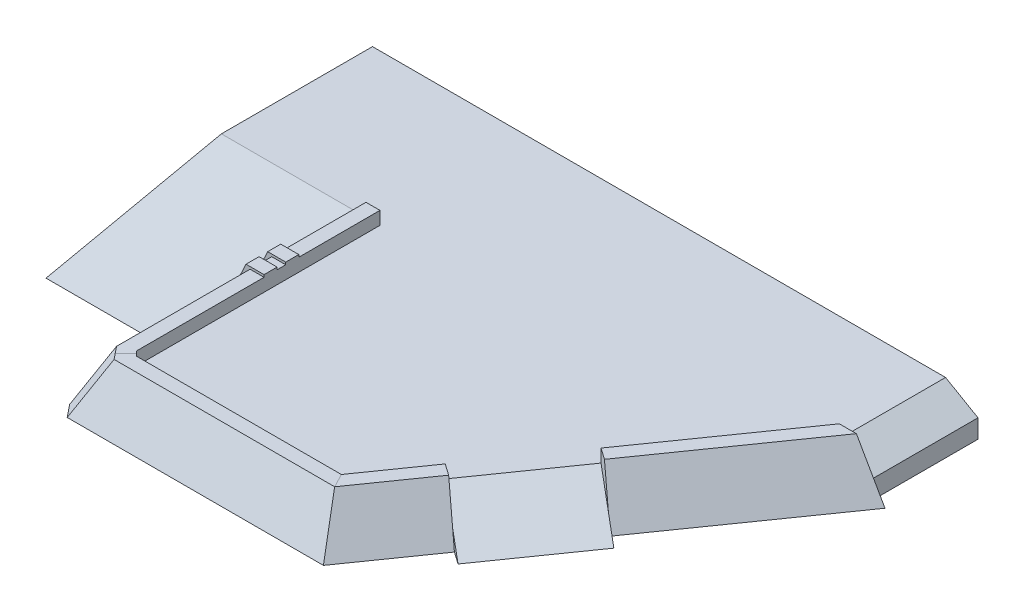
from build123d import *

# Parameters (mm, degrees)
EXTRUDE_1_DEPTH        = 400
EXTRUDE_2_DEPTH        = 1701
EXTRUDE_3_DEPTH        = 1140.074385
CUT_EXTRUDE_1_DEPTH    = 1140.074385
CHAMFER_1_SIZE2        = 124.175097768
CHAMFER_1_SIZE         = 100
CHAMFER_2_SIZE         = 50
EXTRUDE_START          = -870.9
EXTRUDE_4_DEPTH        = 140
PATTERN_LINEAR_1_COUNT = 2
PATTERN_LINEAR_1_PITCH = 232.7
EXTRUDE_START_2        = -800
EXTRUDE_5_DEPTH        = 1200
CUT_EXTRUDE_START      = -800
CUT_EXTRUDE_2_DEPTH    = 1200
CUT_EXTRUDE_START_2    = 6495.820323
SKETCH_9_W             = 1140.074385167
SKETCH_9_H             = 400
CUT_EXTRUDE_3_DEPTH    = 345


with BuildPart() as part:
    # Sketch 1 → Extrude 1 (new body)
    with BuildSketch(Plane(origin=(0, 0, 0), x_dir=(1, 0, 0), z_dir=(0, 1, 0))):
        Polygon((0, 0), (6148, 0), (6148, -1140.074385167), (3948, -4282), (1701, -4282), (1701, -1621), (0, -1621), align=None)
    extrude(amount=EXTRUDE_1_DEPTH)

    # Sketch 2 → Extrude 2 (add)
    with BuildSketch(Plane.ZY.offset(-1701)):
        Polygon((1621, 400), (3502.852043791, 0), (1621, 0), align=None)
    extrude(amount=EXTRUDE_2_DEPTH)

    # Sketch 3 → Extrude 3 (add)
    with BuildSketch(Plane(origin=(0, 0, 0), x_dir=(-1, 0, 0), z_dir=(0, 0, -1))):
        Polygon((-6148, 400), (-6148, 0), (-6840.820323028, 0), align=None)
    extrude(amount=-EXTRUDE_3_DEPTH)

    # Sweep 2: sweep along a path in Sketch 5
    with BuildLine(Plane(origin=(0, 400, 0), x_dir=(1, 0, 0), z_dir=(0, 1, 0))) as sweep_2_path:
        Line((1701, -1621), (1701, -4282))
        Line((1701, -4282), (3948, -4282))
        Line((3948, -4282), (6434.788218176, -730.498363023))
    # Sketch 4 → Sweep 2 (sweep)
    with BuildSketch(Plane.XY.offset(3282)):
        Polygon((1701, 400), (1701, 539.392949833), (1551, 539.392949833), (1299.476936738, 0), (1701, 0), align=None)
    sweep(path=sweep_2_path.line, transition=Transition.RIGHT)

    # Sketch 6 → Cut-Extrude 1 (cut)
    with BuildSketch(Plane(origin=(0, 0, 0), x_dir=(-1, 0, 0), z_dir=(0, 0, -1))):
        Polygon((-6148, 400), (-6148, 600), (-6840.820323028, 600), (-6840.820323028, 0), align=None)
    extrude(amount=-CUT_EXTRUDE_1_DEPTH, mode=Mode.SUBTRACT)

    # Chamfer 1
    chamfer_1_edges = [part.edges().sort_by_distance(p)[0] for p in [
        (1425.238468369, 269.696474917, 4557.761531631),
    ]]
    chamfer(chamfer_1_edges, length=CHAMFER_1_SIZE, length2=CHAMFER_1_SIZE2)

    # Chamfer 2
    chamfer_2_edges = [part.edges().sort_by_distance(p)[0] for p in [
        (1701, 469.696474917, 4282),
    ]]
    chamfer(chamfer_2_edges, length=CHAMFER_2_SIZE)

    # Sketch 7 → Extrude 4 (add)
    with BuildSketch(Plane(origin=(0, 0, 1621), x_dir=(-1, 0, 0), z_dir=(0, 0, -1)).offset(EXTRUDE_START)):
        Polygon((-1701, 0), (-1701, 564.392949833), (-1507.488795506, 564.392949833), (-1244.30804079, 0), align=None)
    extrude_4 = extrude(amount=-EXTRUDE_4_DEPTH)

    # Pattern Linear 1: Extrude 4 ×2
    with Locations(*[(0, 0, i * PATTERN_LINEAR_1_PITCH) for i in range(1, PATTERN_LINEAR_1_COUNT)]):
        add(extrude_4)

    # Sketch 8 → Extrude 5 (add)
    with BuildSketch(Plane(origin=(3948, 539.392949833, 4282), x_dir=(0.819152044, 0, 0.573576436), z_dir=(-0.573576436, 0, 0.819152044)).offset(EXTRUDE_START_2)):
        Polygon((0, -539.392949833), (0, -139.392949833), (560.779317791, -539.392949833), align=None)
    extrude(amount=-EXTRUDE_5_DEPTH)

    # Sketch 8_3 → Cut-Extrude 2 (cut)
    with BuildSketch(Plane(origin=(3948, 539.392949833, 4282), x_dir=(0.819152044, 0, 0.573576436), z_dir=(-0.573576436, 0, 0.819152044)).offset(CUT_EXTRUDE_START)):
        Polygon((0, 260.607050167), (560.779317791, -539.392949833), (0, -139.392949833), align=None)
    extrude(amount=-CUT_EXTRUDE_2_DEPTH, mode=Mode.SUBTRACT)

    # Sketch 9 → Cut-Extrude 3 (cut)
    with BuildSketch(Plane(origin=(0, 0, 0), x_dir=(0, 0, -1), z_dir=(1, 0, 0)).offset(CUT_EXTRUDE_START_2)):
        with Locations((-570.037192584, 200)):
            Rectangle(SKETCH_9_W, SKETCH_9_H)
    extrude(amount=CUT_EXTRUDE_3_DEPTH, mode=Mode.SUBTRACT)


solid = part.part
